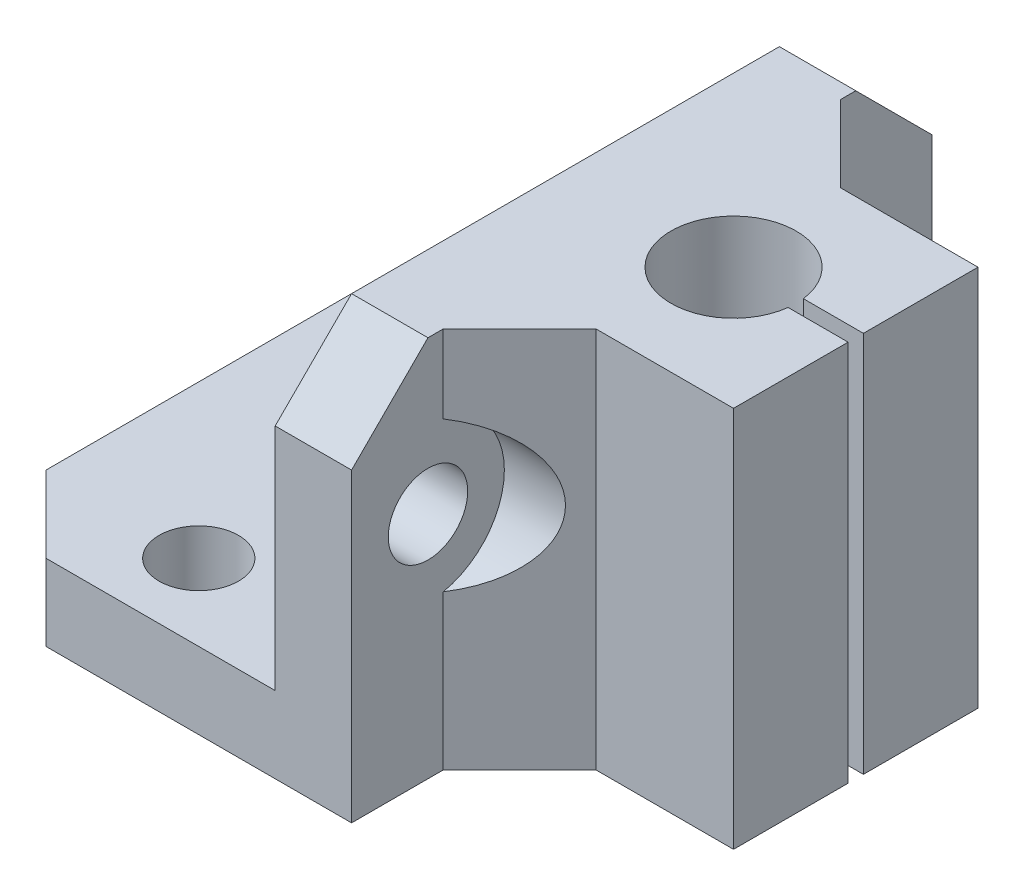
from build123d import *

# Parameters (mm, degrees)
SKETCH1_W           = 20
SKETCH1_H           = 38
SKETCH1_R           = 2.6
BOSS_EXTRUDE1_DEPTH = 5
BOSS_EXTRUDE2_DEPTH = 25
CHAMFER1_SIZE       = 5
SKETCH2_R           = 2.6
CUT_EXTRUDE1_DEPTH  = 50.689032995
SKETCH3_R           = 5
CUT_EXTRUDE2_DEPTH  = 52.903757089
CHAMFER2_SIZE       = 5
CHAMFER3_SIZE       = 5


with BuildPart() as part:
    # Sketch1 → Boss-Extrude1 (new body)
    with BuildSketch(Plane(origin=(0, 0, 0), x_dir=(1, 0, 0), z_dir=(0, 1, 0))):
        with Locations((10, -19)):
            Rectangle(SKETCH1_W, SKETCH1_H)
        with Locations((10, -33)):
            Circle(SKETCH1_R, mode=Mode.SUBTRACT)
        with Locations((10, -5)):
            Circle(SKETCH1_R, mode=Mode.SUBTRACT)
    extrude(amount=BOSS_EXTRUDE1_DEPTH)

    # Sketch1_4 → Boss-Extrude2 (add)
    with BuildSketch(Plane(origin=(0, 0, 0), x_dir=(1, 0, 0), z_dir=(0, 1, 0))):
        with BuildLine():
            Line((25, 0), (20, 0))
            Line((20, 0), (20, -38))
            Line((20, -38), (25, -38))
            Line((25, -38), (25, -27))
            Line((25, -27), (39, -27))
            Line((39, -27), (39, -19.5))
            Line((39, -19.5), (35.06939799, -19.5))
            ThreePointArc((35.06939799, -19.5), (26.9, -19), (35.06939799, -18.5))
            Line((35.06939799, -18.5), (39, -18.5))
            Line((39, -18.5), (39, -11))
            Line((39, -11), (25, -11))
            Line((25, -11), (25, 0))
        make_face()
    extrude(amount=BOSS_EXTRUDE2_DEPTH)

    # Chamfer1
    chamfer1_edges = [part.edges().sort_by_distance(p)[0] for p in [
        (25, 12.5, 11),
        (25, 12.5, 27),
    ]]
    chamfer(chamfer1_edges, length=CHAMFER1_SIZE)

    # Sketch2 → Cut-Extrude1 (cut, through all)
    with BuildSketch(Plane.ZY.offset(-20)):
        with Locations((5, 15)):
            Circle(SKETCH2_R)
        with Locations((33, 15)):
            Circle(SKETCH2_R)
    extrude(amount=-CUT_EXTRUDE1_DEPTH, mode=Mode.SUBTRACT)

    # Sketch3 → Cut-Extrude2 (cut, through all)
    with BuildSketch(Plane.ZY.offset(-25)):
        with Locations((5, 15)):
            Circle(SKETCH3_R)
        with Locations((33, 15)):
            Circle(SKETCH3_R)
    extrude(amount=-CUT_EXTRUDE2_DEPTH, mode=Mode.SUBTRACT)

    # Chamfer2
    chamfer2_edges = [part.edges().sort_by_distance(p)[0] for p in [
        (22.5, 25, 0),
        (22.5, 25, 38),
    ]]
    chamfer(chamfer2_edges, length=CHAMFER2_SIZE)

    # Chamfer3
    chamfer3_edges = [part.edges().sort_by_distance(p)[0] for p in [
        (0, 2.5, 0),
        (0, 2.5, 38),
    ]]
    chamfer(chamfer3_edges, length=CHAMFER3_SIZE)


solid = part.part
